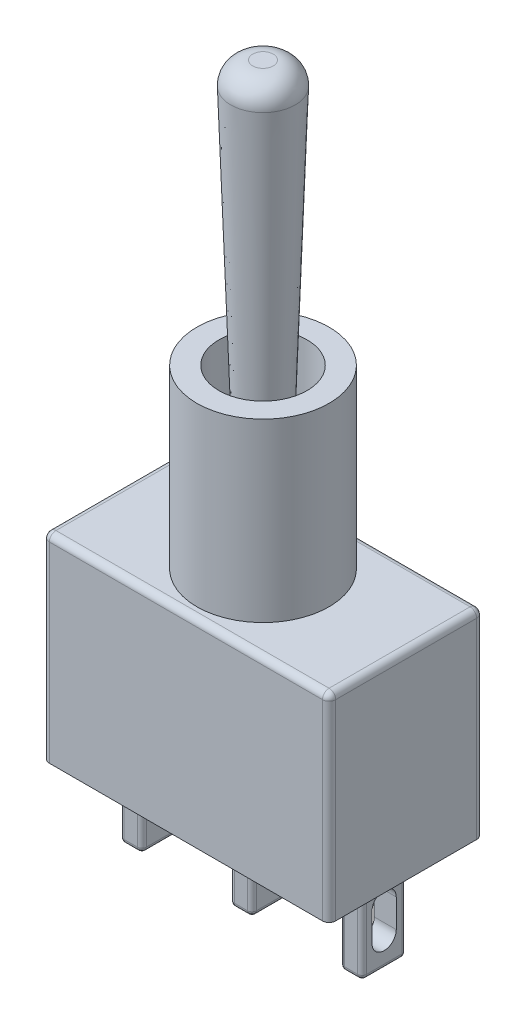
from build123d import *

# Parameters (mm, degrees)
SKETCH1_W           = 13
SKETCH1_H           = 7
BOSS_EXTRUDE1_DEPTH = 9
SKETCH1_3_W         = 1
SKETCH1_3_H         = 2
BOSS_EXTRUDE2_DEPTH = 4
SKETCH2_R           = 3
SKETCH2_R_2         = 2
BOSS_EXTRUDE3_DEPTH = 8
SKETCH2_6_R         = 2
BOSS_EXTRUDE4_DEPTH = 5
SKETCH4_R           = 1
SKETCH3_R           = 1.5
FILLET1_R           = 1
CUT_EXTRUDE1_DEPTH  = 12
FILLET2_R           = 0.3
FILLET3_R           = 0.2


with BuildPart() as part:
    # Sketch1 → Boss-Extrude1 (new body)
    with BuildSketch(Plane(origin=(0, 0, 0), x_dir=(1, 0, 0), z_dir=(0, 1, 0))):
        Rectangle(SKETCH1_W, SKETCH1_H)
    extrude(amount=BOSS_EXTRUDE1_DEPTH)

    # Sketch1_3 → Boss-Extrude2 (add)
    with BuildSketch(Plane(origin=(0, 0, 0), x_dir=(1, 0, 0), z_dir=(0, 1, 0))):
        Rectangle(SKETCH1_3_W, SKETCH1_3_H)
        with Locations((5, 0)):
            Rectangle(SKETCH1_3_W, SKETCH1_3_H)
        with Locations((-5, 0)):
            Rectangle(SKETCH1_3_W, SKETCH1_3_H)
    extrude(amount=-BOSS_EXTRUDE2_DEPTH)

    # Sketch2 → Boss-Extrude3 (add)
    with BuildSketch(Plane(origin=(0, 9, 0), x_dir=(1, 0, 0), z_dir=(0, 1, 0))):
        Circle(SKETCH2_R)
        Circle(SKETCH2_R_2, mode=Mode.SUBTRACT)
    extrude(amount=BOSS_EXTRUDE3_DEPTH)

    # Sketch2_6 → Boss-Extrude4 (add)
    with BuildSketch(Plane(origin=(0, 9, 0), x_dir=(1, 0, 0), z_dir=(0, 1, 0))):
        Circle(SKETCH2_6_R)
    extrude(amount=BOSS_EXTRUDE4_DEPTH)

    # Sketch4 → Loft1 section 0
    with BuildSketch(Plane(origin=(0, 14, 0), x_dir=(1, 0, 0), z_dir=(0, 1, 0))):
        Circle(SKETCH4_R)
    # Sketch3 → Loft1 section 1
    with BuildSketch(Plane(origin=(0, 29, 0), x_dir=(1, 0, 0), z_dir=(0, 1, 0))):
        Circle(SKETCH3_R)
    loft()

    # Fillet1
    fillet1_edges = [part.edges().sort_by_distance(p)[0] for p in [
        (-1.5, 29, 0),
    ]]
    fillet(fillet1_edges, radius=FILLET1_R)

    # Sketch5 → Cut-Extrude1 (cut)
    with BuildSketch(Plane.ZY.offset(5.5)):
        with BuildLine():
            Line((0.550014323, -1.43369619), (0.550014323, -2.717062944))
            ThreePointArc((0.550014323, -2.717062944), (0, -3.267077268), (-0.550014323, -2.717062944))
            Line((-0.550014323, -2.717062944), (-0.550014323, -1.43369619))
            ThreePointArc((-0.550014323, -1.43369619), (0, -0.883681867), (0.550014323, -1.43369619))
        make_face()
    extrude(amount=-CUT_EXTRUDE1_DEPTH, mode=Mode.SUBTRACT)

    # Fillet2
    fillet2_edges = [part.edges().sort_by_distance(p)[0] for p in [
        (6.5, 4.5, -3.5),
        (-6.5, 4.5, -3.5),
        (-6.5, 9, 0),
        (6.5, 4.5, 3.5),
        (0, 9, 3.5),
        (-6.5, 4.5, 3.5),
        (0, 9, -3.5),
        (6.5, 9, 0),
    ]]
    fillet(fillet2_edges, radius=FILLET2_R)

    # Fillet3
    fillet3_edges = [part.edges().sort_by_distance(p)[0] for p in [
        (-4.5, -2, 1),
        (-5.5, -2, 1),
        (-5.5, -4, 0),
        (-5, -4, 1),
        (-4.5, -4, 0),
        (-5, -4, -1),
        (-4.5, -2, -1),
        (-5.5, -2, -1),
        (0.5, -2, 1),
        (0.5, -4, 0),
        (0, -4, 1),
        (5, -4, 1),
        (5, -4, -1),
        (0, -4, -1),
        (0.5, -2, -1),
        (-0.5, -2, 1),
        (-0.5, -4, 0),
        (-0.5, -2, -1),
        (4.5, -2, 1),
        (4.5, -4, 0),
        (4.5, -2, -1),
        (5.5, -2, 1),
        (5.5, -4, 0),
        (5.5, -2, -1),
    ]]
    fillet(fillet3_edges, radius=FILLET3_R)


solid = part.part
